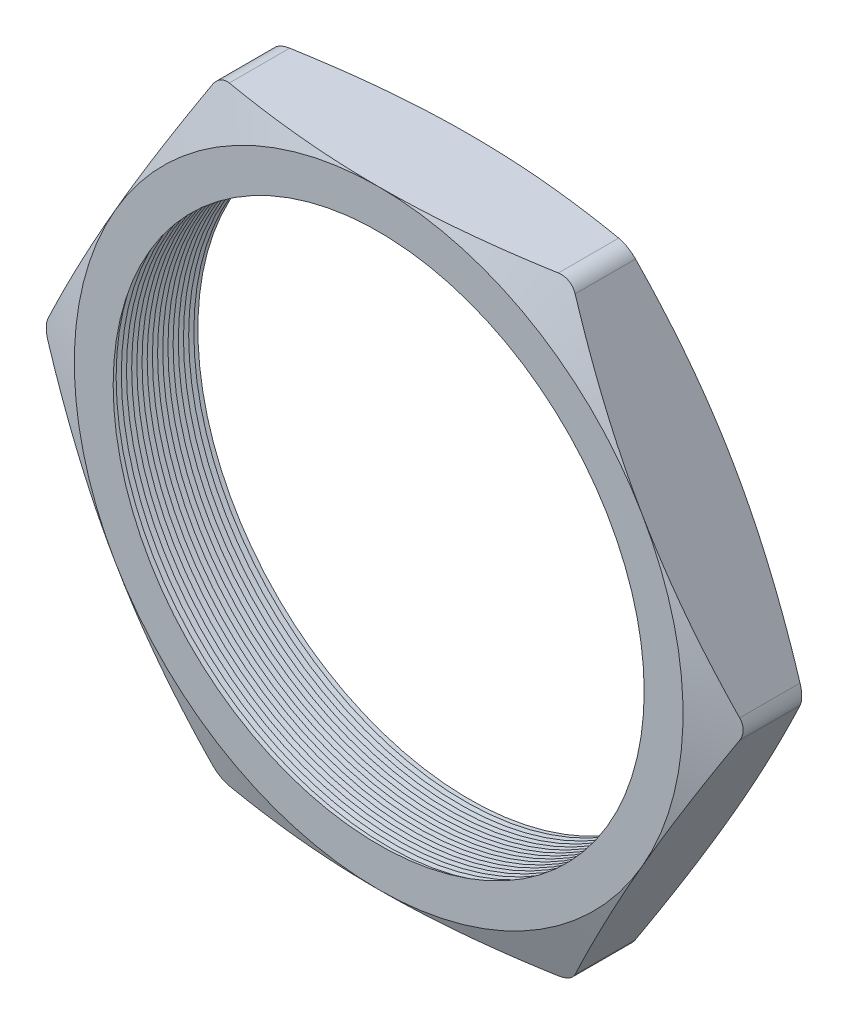
from build123d import *

# Parameters (mm, degrees)
SKETCH1_R          = 10.414
EXTRUDE1_DEPTH     = 3.556
FILLET1_R          = 0.762
SKETCH2_OUTSIDE_W  = 61.662
SKETCH2_OUTSIDE_H  = 58.204
SKETCH2_OUTSIDE_R  = 11.938
CUT_EXTRUDE1_DEPTH = 4.556
CUT_EXTRUDE1_DRAFT = -70
SKETCH3_OUTSIDE_W  = 61.662
SKETCH3_OUTSIDE_H  = 58.204
SKETCH3_OUTSIDE_R  = 11.938
CUT_EXTRUDE2_DEPTH = 4.5560001
CUT_EXTRUDE2_DRAFT = -70
LPATTERN1_COUNT    = 18
LPATTERN1_PITCH    = 0.2032


with BuildPart() as part:
    # Sketch1 → Extrude1 (new body)
    with BuildSketch(Plane.XY):
        Polygon((-13.784815027, 0), (-6.892407514, -11.938), (6.892407514, -11.938), (13.784815027, 0), (6.892407514, 11.938), (-6.892407514, 11.938), align=None)
        Circle(SKETCH1_R, mode=Mode.SUBTRACT)
    extrude(amount=EXTRUDE1_DEPTH)

    # Fillet1
    fillet1_edges = [part.edges().sort_by_distance(p)[0] for p in [
        (13.784815027, 0, 1.778),
        (6.892407514, -11.938, 1.778),
        (-6.892407514, -11.938, 1.778),
        (-13.784815027, 0, 1.778),
        (-6.892407514, 11.938, 1.778),
        (6.892407514, 11.938, 1.778),
    ]]
    fillet(fillet1_edges, radius=FILLET1_R)


with BuildPart() as cut_extrude1_tool:
    # Sketch2 outside → Cut-Extrude1 (with draft: the straight prism first)
    with BuildSketch(Plane.XY.offset(3.556)):
        Rectangle(SKETCH2_OUTSIDE_W, SKETCH2_OUTSIDE_H)
        Circle(SKETCH2_OUTSIDE_R, mode=Mode.SUBTRACT)
    extrude(amount=-CUT_EXTRUDE1_DEPTH)
    # Cut-Extrude1: the draft: its side faces are tilted about the plane it starts from
    cut_extrude1_sides = [cut_extrude1_tool.faces().sort_by_distance(p)[0] for p in [
        (0, -29.102, 1.278),
        (30.831, 0, 1.278),
        (0, 29.102, 1.278),
        (-30.831, 0, 1.278),
        (-11.938, 0, 1.278),
    ]]
    draft(cut_extrude1_sides, Plane.XY.offset(3.556), CUT_EXTRUDE1_DRAFT)


with BuildPart() as part_1:
    add(part.part)

    # Cut-Extrude1: cut by cut_extrude1_tool
    add(cut_extrude1_tool.part, mode=Mode.SUBTRACT)


with BuildPart() as cut_extrude2_tool:
    # Sketch3 outside → Cut-Extrude2 (with draft: the straight prism first)
    with BuildSketch(Plane(origin=(0, 0, 0), x_dir=(-1, 0, 0), z_dir=(0, 0, -1))):
        Rectangle(SKETCH3_OUTSIDE_W, SKETCH3_OUTSIDE_H)
        Circle(SKETCH3_OUTSIDE_R, mode=Mode.SUBTRACT)
    extrude(amount=-CUT_EXTRUDE2_DEPTH)
    # Cut-Extrude2: the draft: its side faces are tilted about the plane it starts from
    cut_extrude2_sides = [cut_extrude2_tool.faces().sort_by_distance(p)[0] for p in [
        (0, -29.102, 2.27800005),
        (-30.831, 0, 2.27800005),
        (0, 29.102, 2.27800005),
        (30.831, 0, 2.27800005),
        (11.938, 0, 2.27800005),
    ]]
    draft(cut_extrude2_sides, Plane(origin=(0, 0, 0), x_dir=(-1, 0, 0), z_dir=(0, 0, -1)), CUT_EXTRUDE2_DRAFT)


with BuildPart() as part_2:
    add(part_1.part)

    # Cut-Extrude2: cut by cut_extrude2_tool
    add(cut_extrude2_tool.part, mode=Mode.SUBTRACT)

    # Sketch4 → Cut-Revolve1 (revolve, cut)
    with BuildSketch(Plane(origin=(0, 0, 0), x_dir=(1, 0, 0), z_dir=(0, 1, 0))):
        Polygon((-10.414, -3.556), (-10.414, -3.116059095), (-10.795, -3.336029547), align=None)
    cut_revolve1 = revolve(axis=Axis((0, 0, 3.556), (0, 0, -1)), mode=Mode.SUBTRACT)

    # LPattern1: Cut-Revolve1 ×18
    with Locations(*[(0, 0, -i * LPATTERN1_PITCH) for i in range(1, LPATTERN1_COUNT)]):
        add(cut_revolve1, mode=Mode.SUBTRACT)


solid = part_2.part
